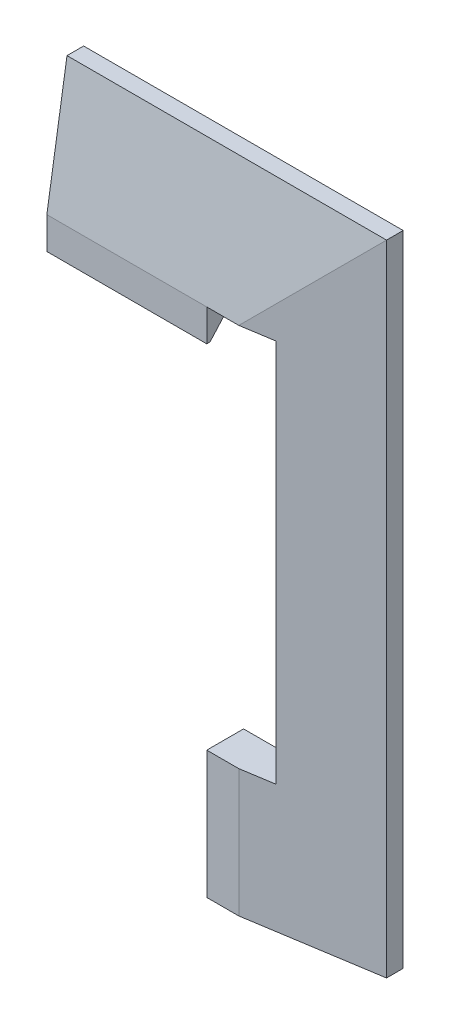
from build123d import *

# Parameters (mm, degrees)
DODANIE_WYCI_GNI_CIE1_DEPTH = 5.2
SZKIC3_W                    = 60
SZKIC3_H                    = 159.9
SZKIC5_W                    = 99.9
SZKIC5_H                    = 199.8
SZKIC6_W                    = 49.271239353
SZKIC6_H                    = 120
WYTNIJ_WYCI_GNI_CIE1_DEPTH  = 78
WYTNIJ_WYCI_GNI_CIE2_DEPTH  = 5.6
SZKIC9_R                    = 2.424871131
SZKIC9_R_2                  = 1.2
DODANIE_WYCI_GNI_CIE3_DEPTH = 3.8
SZKIC10_W                   = 50
SZKIC10_H                   = 39.9
WYTNIJ_WYCI_GNI_CIE4_DEPTH  = 24
DODANIE_WYCI_GNI_CIE4_DEPTH = 50


with BuildPart() as part:
    # Szkic2 → Dodanie-wyciągnięcie1 (new body)
    with BuildSketch(Plane.XY):
        Polygon((18.542832418, 83.245366469), (18.542832418, 43.345366469), (-51.457167582, 43.345366469), (-51.457167582, -76.654633531), (18.542832418, -76.654633531), (18.542832418, -116.554633531), (-81.357167582, -116.554633531), (-81.357167582, 83.245366469), align=None)
    extrude(amount=DODANIE_WYCI_GNI_CIE1_DEPTH)

    # Szkic3 → Wyciągnięcie po profilach3 section 0
    with BuildSketch(Plane.XY.offset(11.5)):
        with Locations((-11.457167582, 3.295366469)):
            Rectangle(SZKIC3_W, SZKIC3_H)
    # Szkic5 → Wyciągnięcie po profilach3 section 1
    with BuildSketch(Plane.XY.offset(5.2)):
        with Locations((-31.407167582, -16.654633531)):
            Rectangle(SZKIC5_W, SZKIC5_H)
    loft()

    # Szkic6 → Wytnij-wyciągnięcie1 (cut)
    with BuildSketch(Plane(origin=(-51.457167582, 0, 0), x_dir=(0, 0, -1), z_dir=(1, 0, 0))):
        with Locations((-24.635619677, -16.654633531)):
            Rectangle(SZKIC6_W, SZKIC6_H)
    extrude(amount=WYTNIJ_WYCI_GNI_CIE1_DEPTH, mode=Mode.SUBTRACT)

    # Szkic7 → Wytnij-wyciągnięcie2 (cut)
    with BuildSketch(Plane(origin=(-51.457167582, 0, 0), x_dir=(0, 0, -1), z_dir=(1, 0, 0))):
        Polygon((-5.12, -34.1297624), (-7.22, -35.342197966), (-7.22, -37.767069096), (-5.12, -38.979504662), (-3.02, -37.767069096), (-3.02, -35.342197966), align=None)
        Polygon((-5.12, 5.6702376), (-7.22, 4.457802034), (-7.22, 2.032930904), (-5.12, 0.820495338), (-3.02, 2.032930904), (-3.02, 4.457802034), align=None)
    extrude(amount=-WYTNIJ_WYCI_GNI_CIE2_DEPTH, mode=Mode.SUBTRACT)

    # Szkic9 → Dodanie-wyciągnięcie3 (add)
    with BuildSketch(Plane(origin=(-51.457167582, 0, 0), x_dir=(0, 0, -1), z_dir=(1, 0, 0))):
        with Locations((-5.12, 3.245366469)):
            Circle(SZKIC9_R)
        with Locations((-5.12, 3.245366469)):
            Circle(SZKIC9_R_2, mode=Mode.SUBTRACT)
        with Locations((-5.12, -36.554633531)):
            Circle(SZKIC9_R)
        with Locations((-5.12, -36.554633531)):
            Circle(SZKIC9_R_2, mode=Mode.SUBTRACT)
    extrude(amount=-DODANIE_WYCI_GNI_CIE3_DEPTH)

    # Szkic10 → Wytnij-wyciągnięcie4 (cut)
    with BuildSketch(Plane.XY.offset(11.5)):
        with Locations((-6.457167582, 63.295366469)):
            Rectangle(SZKIC10_W, SZKIC10_H)
    extrude(amount=-WYTNIJ_WYCI_GNI_CIE4_DEPTH, mode=Mode.SUBTRACT)


with BuildPart() as body_2:
    # Lustro1: mirrored copy
    add(part.part.mirror(Plane(origin=(18.542832418, 83.245366469, 5.2), x_dir=(0, 0, 1), z_dir=(-1, 0, 0))))


with BuildPart() as body_2_1:
    # Obiekt-Przenieś/Kopiuj1: moved
    add(body_2.part.moved(Location((34.890139481, 0, 0))))

    # Szkic11 → Dodanie-wyciągnięcie4 (add)
    with BuildSketch(Plane.ZY.offset(-53.432971899)):
        Polygon((11.5, -76.654633531), (1.5, -76.654633531), (10.5, -66.654633531), (11.5, -66.654633531), align=None)
    extrude(amount=-DODANIE_WYCI_GNI_CIE4_DEPTH)


with BuildPart() as body_2_2:
    # Lustro2: mirrored copy
    add(body_2_1.part.mirror(Plane(origin=(153.332971899, 83.245366469, 5.2), x_dir=(0, 0, 1), z_dir=(0, -1, 0))))


solid = body_2_2.part
